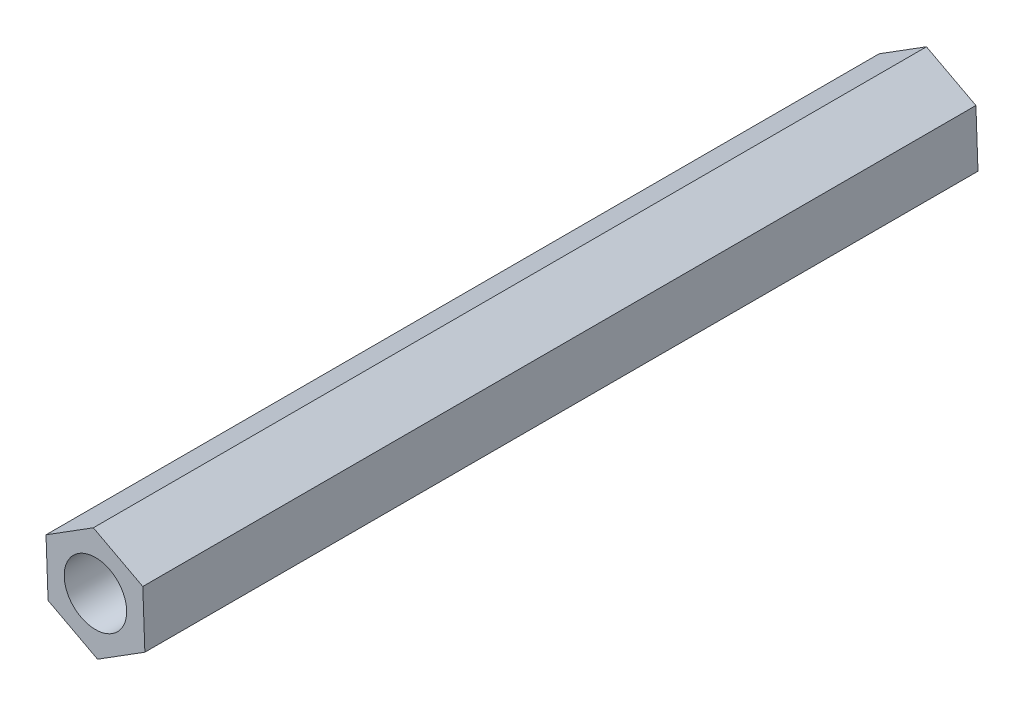
from build123d import *

# Parameters (mm, degrees)
SKETCH_1_R      = 1.5
EXTRUDE_1_DEPTH = 40


with BuildPart() as part:
    # 草图1 → 凸台-拉伸1 (new body)
    with BuildSketch(Plane.XY):
        Polygon((2.273206082, 1.428297627), (-0.100338988, 2.682803028), (-2.37354507, 1.254505402), (-2.273206082, -1.428297627), (0.100338988, -2.682803028), (2.37354507, -1.254505402), align=None)
        Circle(SKETCH_1_R, mode=Mode.SUBTRACT)
    extrude(amount=EXTRUDE_1_DEPTH)


solid = part.part
